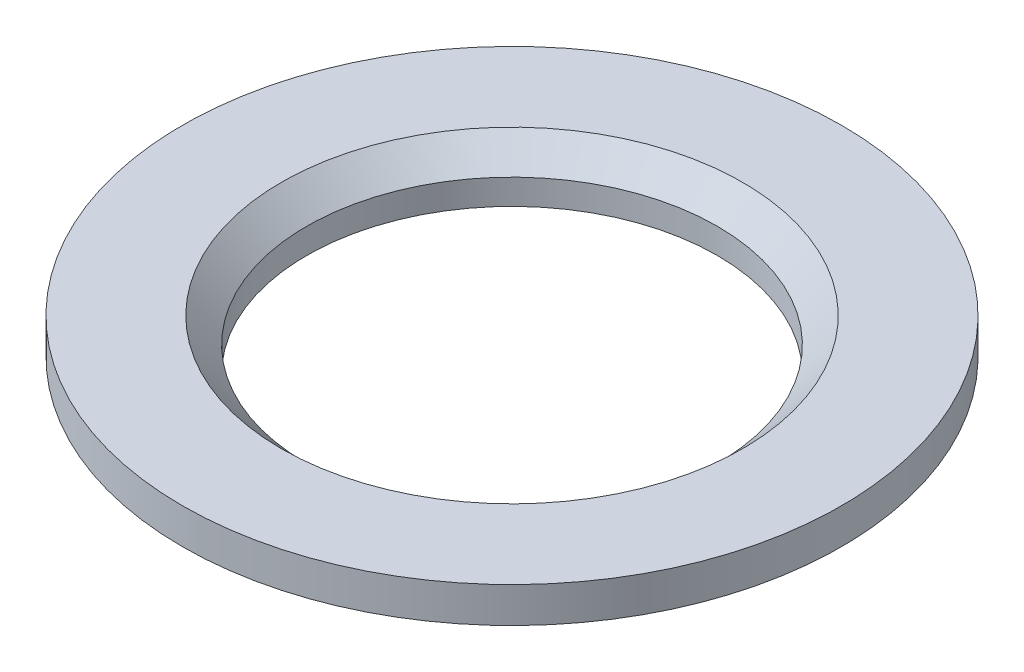
from build123d import *


with BuildPart() as part:
    # Sketch1 → Revolve1 (revolve)
    with BuildSketch(Plane.XY):
        Polygon((4.05, 0.5), (4.55, 1), (6.5, 1), (6.5, 0.3), (4.8, 0.3), (4.5, 0), (4.05, 0), align=None)
    revolve(axis=Axis((0, 2.763503086, 0), (0, -1, 0)))


solid = part.part
